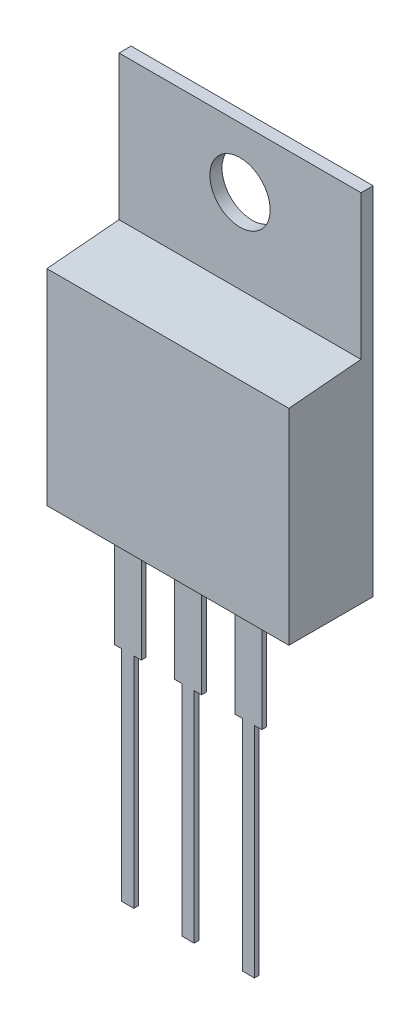
from build123d import *

# Parameters (mm, degrees)
SKETCH1_W           = 10.2
SKETCH1_H           = 15
BOSS_EXTRUDE1_DEPTH = 0.51
SKETCH2_W           = 10.2
SKETCH2_H           = 8.65
BOSS_EXTRUDE2_DEPTH = 3.04
DRAFT1_ANGLE        = 5
SKETCH3_W           = 0.2
SKETCH3_H           = 4.5
EXTRUDE_THIN1_DEPTH = 0.57
SKETCH4_W           = 0.2
SKETCH4_H           = 9.22
EXTRUDE_THIN2_DEPTH = 0.255
LPATTERN1_COUNT     = 3
LPATTERN1_PITCH     = 2.54
CUT_EXTRUDE1_REACH  = 2.51
SKETCH5_R           = 1.27


with BuildPart() as part:
    # Sketch1 → Boss-Extrude1 (new body)
    with BuildSketch(Plane.XY):
        with Locations((5.1, 7.5)):
            Rectangle(SKETCH1_W, SKETCH1_H)
    extrude(amount=BOSS_EXTRUDE1_DEPTH)

    # Sketch2 → Boss-Extrude2 (add)
    with BuildSketch(Plane.XY.offset(0.51)):
        with Locations((5.1, 4.325)):
            Rectangle(SKETCH2_W, SKETCH2_H)
    extrude(amount=BOSS_EXTRUDE2_DEPTH)

    # Draft1
    draft1_faces = [part.faces().sort_by_distance(p)[0] for p in [
        (5.1, 8.65, 2.03),
    ]]
    draft(draft1_faces, Plane.XY.offset(3.55), DRAFT1_ANGLE)

    # Sketch3 → Extrude-Thin1 (add, symmetric)
    with BuildSketch(Plane.ZY.offset(-2.56)):
        with Locations((2.6, -2.25)):
            Rectangle(SKETCH3_W, SKETCH3_H)
    extrude_thin1 = extrude(amount=EXTRUDE_THIN1_DEPTH, both=True)

    # Sketch4 → Extrude-Thin2 (add, symmetric)
    with BuildSketch(Plane.ZY.offset(-2.56)):
        with Locations((2.6, -9.11)):
            Rectangle(SKETCH4_W, SKETCH4_H)
    extrude_thin2 = extrude(amount=EXTRUDE_THIN2_DEPTH, both=True)

    # LPattern1: Extrude-Thin1, Extrude-Thin2 ×3
    with Locations(*[(i * LPATTERN1_PITCH, 0, 0) for i in range(1, LPATTERN1_COUNT)]):
        add(extrude_thin1)
        add(extrude_thin2)

    # Sketch5 → Cut-Extrude1 (cut, up to next)
    with BuildSketch(Plane.XY.offset(0.51), mode=Mode.PRIVATE) as cut_extrude1_sk1:
        with Locations((5.1, 12.46)):
            Circle(SKETCH5_R)
    cut_extrude1_tool1 = extrude(cut_extrude1_sk1.sketch, amount=-CUT_EXTRUDE1_REACH, mode=Mode.PRIVATE) & part.part
    add(cut_extrude1_tool1.solids().sort_by_distance((5.1, 12.46, 0.51))[0], mode=Mode.SUBTRACT)


solid = part.part
